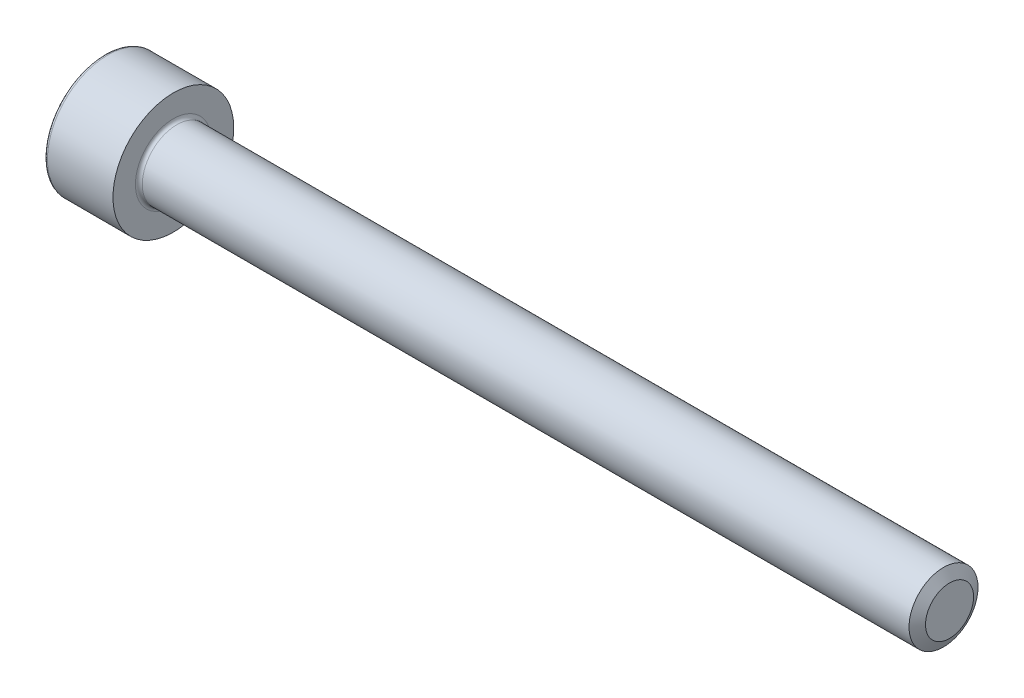
from build123d import *

# Parameters (mm, degrees)
SKETCH_1_W          = 4
SKETCH_1_H          = 3.5
SKETCH_2_R          = 2
EXTRUDE_1_DEPTH     = 45
CUT_EXTRUDE_1_DEPTH = 2
CHAMFER_1_SIZE      = 0.6062
CHAMFER_1_SIZE2     = 0.35
FILLET_1_R          = 0.2


with BuildPart() as part:
    # 草图1 → 旋转1 (revolve)
    with BuildSketch(Plane.XY):
        with Locations((2, 1.75)):
            Rectangle(SKETCH_1_W, SKETCH_1_H)
    revolve(axis=Axis((0, 0, 0), (1, 0, 0)))

    # 草图2 → 凸台-拉伸1 (add)
    with BuildSketch(Plane(origin=(4, 0, 0), x_dir=(0, 0, -1), z_dir=(1, 0, 0))):
        Circle(SKETCH_2_R)
    extrude(amount=EXTRUDE_1_DEPTH)

    # 草图3 → 切除-拉伸1 (cut)
    with BuildSketch(Plane.ZY):
        Polygon((0, 1.72), (-1.489563695, 0.86), (-1.489563695, -0.86), (0, -1.72), (1.489563695, -0.86), (1.489563695, 0.86), align=None)
    extrude(amount=-CUT_EXTRUDE_1_DEPTH, mode=Mode.SUBTRACT)

    # 倒角1
    chamfer_1_edges = [part.edges().sort_by_distance(p)[0] for p in [
        (49, 0, 2),
    ]]
    chamfer_1_side = [part.faces().sort_by_distance(p)[0] for p in [
        (49, 0, 0),
    ]]
    chamfer(chamfer_1_edges, length=CHAMFER_1_SIZE, length2=CHAMFER_1_SIZE2, reference=chamfer_1_side[0])

    # 圆角1
    fillet_1_edges = [part.edges().sort_by_distance(p)[0] for p in [
        (0, -3.5, 0),
        (4, 0, 2),
    ]]
    fillet(fillet_1_edges, radius=FILLET_1_R)


solid = part.part
